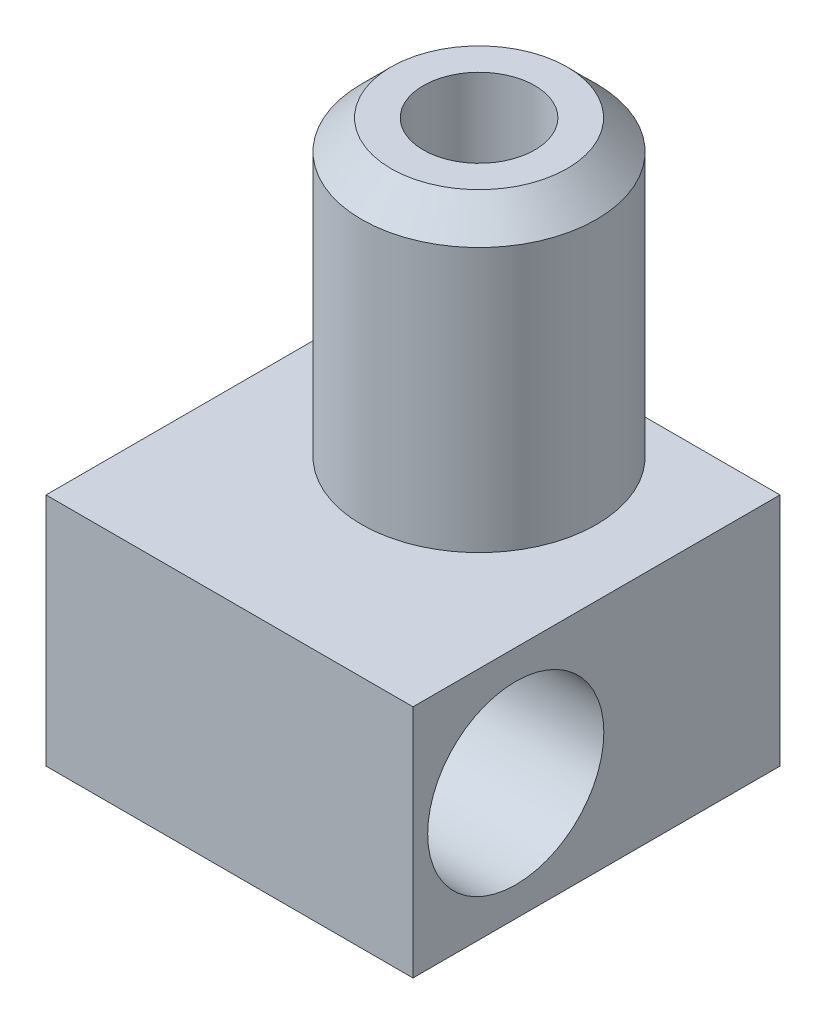
from build123d import *

# Parameters (mm, degrees)
SCHIZZO2_W                   = 12.5
SCHIZZO2_H                   = 12.5
SCHIZZO2_R                   = 0.15
ESTRUSIONE_ESTRUSIONE1_DEPTH = 8
SCHIZZO3_R                   = 3
TAGLIO_ESTRUSIONE1_DEPTH     = 18.102631376
SCHIZZO4_R                   = 0.75
TAGLIO_ESTRUSIONE2_DEPTH     = 3.5
SCHIZZO5_R                   = 4
ESTRUSIONE_ESTRUSIONE2_DEPTH = 10
SMUSSO1_SIZE                 = 1
FORO_3_8_3_8_1_D             = 3.8
FORO_3_8_3_8_1_DEPTH         = 15
FORO_3_8_3_8_1_TIP           = 1.141635176


with BuildPart() as part:
    # Schizzo1 → Rivoluzione1 (revolve)
    with BuildSketch(Plane.XY, mode=Mode.PRIVATE) as rivoluzione1_sk:
        Polygon((-0.15, 0), (-0.15, -3), (-0.5, -3), (-4, -1), (-4, 0), align=None)
    revolve(rivoluzione1_sk.sketch.rotate(Axis((0, -26.528171736, 0), (0, 1, 0)), 270), axis=Axis((0, -26.528171736, 0), (0, 1, 0)))

    # Schizzo2 → Estrusione-Estrusione1 (add)
    with BuildSketch(Plane(origin=(0, 0, 0), x_dir=(1, 0, 0), z_dir=(0, 1, 0))):
        with Locations((0, -2.25)):
            Rectangle(SCHIZZO2_W, SCHIZZO2_H)
        with Locations(Location((0, 0, 0), (0, 0, 90))):
            Circle(SCHIZZO2_R, mode=Mode.SUBTRACT)
    extrude(amount=ESTRUSIONE_ESTRUSIONE1_DEPTH)

    # Schizzo3 → Taglio-Estrusione1 (cut, through all)
    with BuildSketch(Plane(origin=(6.25, 0, 0), x_dir=(0, 0, -1), z_dir=(1, 0, 0))):
        with Locations((-5, 4)):
            Circle(SCHIZZO3_R)
    extrude(amount=-TAGLIO_ESTRUSIONE1_DEPTH, mode=Mode.SUBTRACT)

    # Schizzo4 → Taglio-Estrusione2 (cut)
    with BuildSketch(Plane(origin=(0, 0, -4), x_dir=(-1, 0, 0), z_dir=(0, 0, -1))):
        with Locations((-5.3, 4)):
            Circle(SCHIZZO4_R)
    extrude(amount=-TAGLIO_ESTRUSIONE2_DEPTH, mode=Mode.SUBTRACT)

    # Schizzo5 → Estrusione-Estrusione2 (add)
    with BuildSketch(Plane(origin=(0, 8, 0), x_dir=(1, 0, 0), z_dir=(0, 1, 0))):
        with Locations(Location((0, 0, 0), (0, 0, 90))):
            Circle(SCHIZZO5_R)
    extrude(amount=ESTRUSIONE_ESTRUSIONE2_DEPTH)

    # Smusso1
    smusso1_edges = [part.edges().sort_by_distance(p)[0] for p in [
        (0, 18, 4),
    ]]
    chamfer(smusso1_edges, length=SMUSSO1_SIZE)

    # Foro Ø3.8 (3.8)-1
    with Locations(Plane(origin=(0, 18, 0), x_dir=(1, 0, 0), z_dir=(0, 1, 0))):
        with Locations((0, 0)):
            Hole(FORO_3_8_3_8_1_D / 2, depth=FORO_3_8_3_8_1_DEPTH)
            with Locations((0, 0, -(FORO_3_8_3_8_1_DEPTH + FORO_3_8_3_8_1_TIP / 2))):  # 118° drill point
                Cone(0, FORO_3_8_3_8_1_D / 2, FORO_3_8_3_8_1_TIP, mode=Mode.SUBTRACT)


solid = part.part
